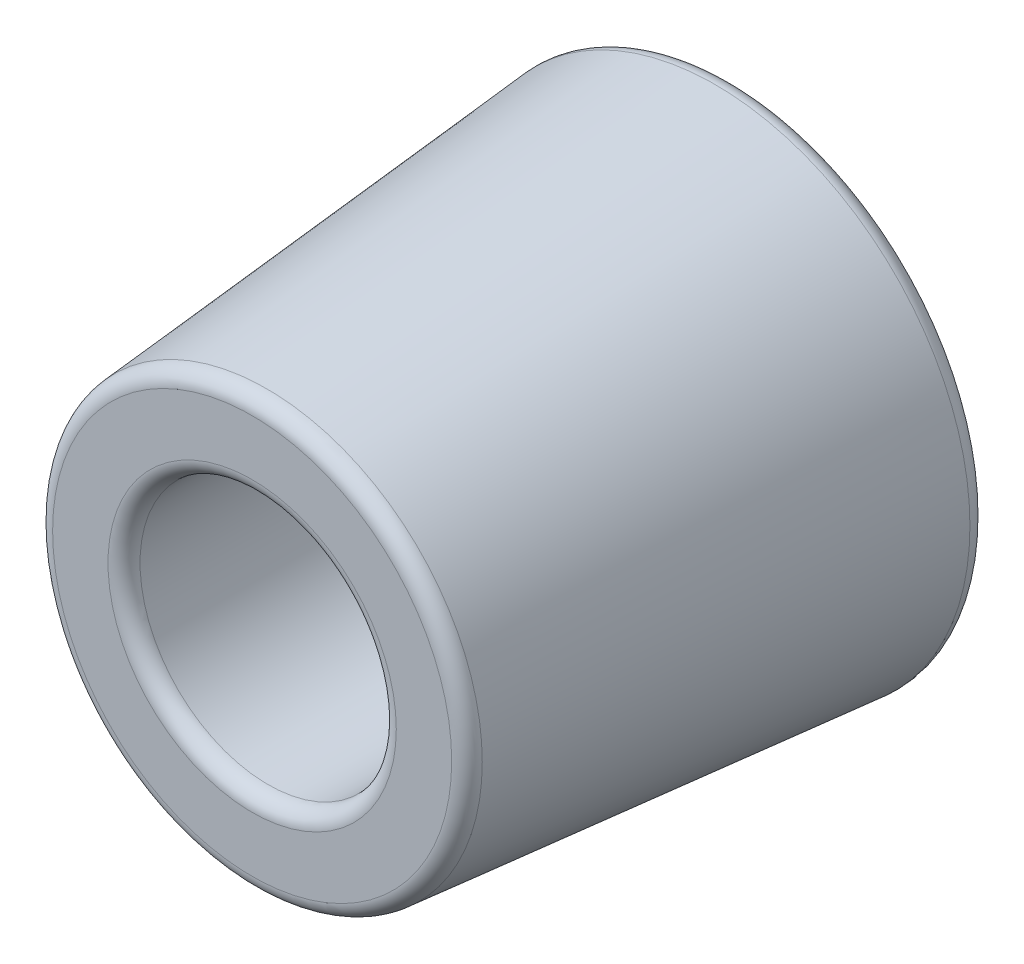
from build123d import *

# Parameters (mm, degrees)
ESQUISSE1_R             = 8
BOSS_EXTRU_1_DEPTH      = 15
BOSS_EXTRU_1_TAPER      = 5
ESQUISSE2_R             = 2.5
ENL_V_MAT_EXTRU_1_DEPTH = 30
ESQUISSE3_R             = 4
ENL_V_MAT_EXTRU_2_DEPTH = 10
CONG_2_R                = 0.5
CONG_3_R                = 0.5
CONG_4_R                = 0.5


with BuildPart() as part:
    # Esquisse1 → Boss.-Extru.1 (new body)
    with BuildSketch(Plane.XY):
        Circle(ESQUISSE1_R)
    extrude(amount=BOSS_EXTRU_1_DEPTH, taper=BOSS_EXTRU_1_TAPER)

    # Esquisse2 → Enlèv. mat.-Extru.1 (cut)
    with BuildSketch(Plane.XY.offset(15)):
        Circle(ESQUISSE2_R)
    extrude(amount=-ENL_V_MAT_EXTRU_1_DEPTH, mode=Mode.SUBTRACT)

    # Esquisse3 → Enlèv. mat.-Extru.2 (cut)
    with BuildSketch(Plane.XY.offset(15)):
        Circle(ESQUISSE3_R)
    extrude(amount=-ENL_V_MAT_EXTRU_2_DEPTH, mode=Mode.SUBTRACT)

    # Congé2
    cong_2_edges = [part.edges().sort_by_distance(p)[0] for p in [
        (-4, 0, 15),
    ]]
    fillet(cong_2_edges, radius=CONG_2_R)

    # Congé3
    cong_3_edges = [part.edges().sort_by_distance(p)[0] for p in [
        (-8, 0, 0),
    ]]
    fillet(cong_3_edges, radius=CONG_3_R)

    # Congé4
    cong_4_edges = [part.edges().sort_by_distance(p)[0] for p in [
        (-6.687670047, 0, 15),
    ]]
    fillet(cong_4_edges, radius=CONG_4_R)


solid = part.part
